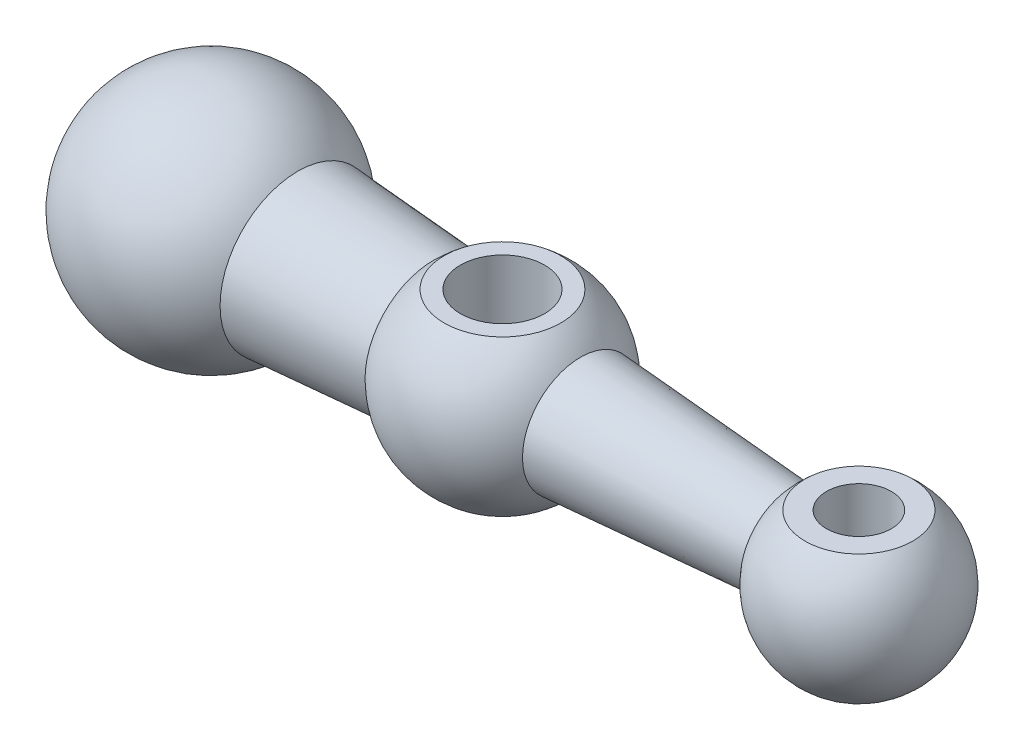
from build123d import *

# Parameters (mm, degrees)
SKETCH3_R               = 6.5
CUT_EXTRUDE1_DEPTH      = 19
CUT_EXTRUDE1_DEPTH_BACK = 19
CUT_EXTRUDE2_START      = 10
SKETCH4_R               = 8.5
CUT_EXTRUDE2_DEPTH      = 10
SKETCH5_R               = 5
CUT_EXTRUDE3_DEPTH      = 10
CUT_EXTRUDE4_START      = 12
SKETCH6_R               = 9
CUT_EXTRUDE4_DEPTH      = 12


with BuildPart() as part:
    # Sketch2 → Revolve1 (revolve)
    with BuildSketch(Plane.XY):
        with BuildLine():
            Line((13.416407865, 12), (34.325156356, 10.537917876))
            ThreePointArc((34.325156356, 10.537917876), (46.046347106, 14.963460754), (57.037551508, 8.949712492))
            Line((57.037551508, 8.949712492), (88.873707199, 6.72351162))
            ThreePointArc((88.873707199, 6.72351162), (103.489856271, 12.522815307), (113, 0))
            Line((113, 0), (-18, 0))
            ThreePointArc((-18, 0), (-6.422797616, 16.815102461), (13.416407865, 12))
        make_face()
    revolve(axis=Axis((-18, 0, 0), (1, 0, 0)))

    # Sketch3 → Cut-Extrude1 (cut, two sides)
    with BuildSketch(Plane(origin=(0, 0, 0), x_dir=(1, 0, 0), z_dir=(0, 1, 0))) as cut_extrude1_sk:
        with Locations((45, 0)):
            Circle(SKETCH3_R)
    extrude(amount=CUT_EXTRUDE1_DEPTH, mode=Mode.SUBTRACT)
    extrude(cut_extrude1_sk.sketch, amount=-CUT_EXTRUDE1_DEPTH_BACK, mode=Mode.SUBTRACT)

    # Sketch4 → Cut-Extrude2 (cut)
    with BuildSketch(Plane(origin=(0, 0, 0), x_dir=(1, 0, 0), z_dir=(0, 1, 0)).offset(CUT_EXTRUDE2_START)):
        with Locations((100, 0)):
            Circle(SKETCH4_R)
    extrude(amount=CUT_EXTRUDE2_DEPTH, mode=Mode.SUBTRACT)

    # Sketch5 → Cut-Extrude3 (cut)
    with BuildSketch(Plane(origin=(0, 10, 0), x_dir=(1, 0, 0), z_dir=(0, 1, 0))):
        with Locations((100, 0)):
            Circle(SKETCH5_R)
    extrude(amount=-CUT_EXTRUDE3_DEPTH, mode=Mode.SUBTRACT)

    # Sketch6 → Cut-Extrude4 (cut)
    with BuildSketch(Plane(origin=(0, 0, 0), x_dir=(1, 0, 0), z_dir=(0, 1, 0)).offset(CUT_EXTRUDE4_START)):
        with Locations((45, 0)):
            Circle(SKETCH6_R)
    cut_extrude4 = extrude(amount=CUT_EXTRUDE4_DEPTH, mode=Mode.SUBTRACT)

    # Mirror1: Cut-Extrude4 across plane
    add(cut_extrude4.mirror(Plane.ZX), mode=Mode.SUBTRACT)


solid = part.part
